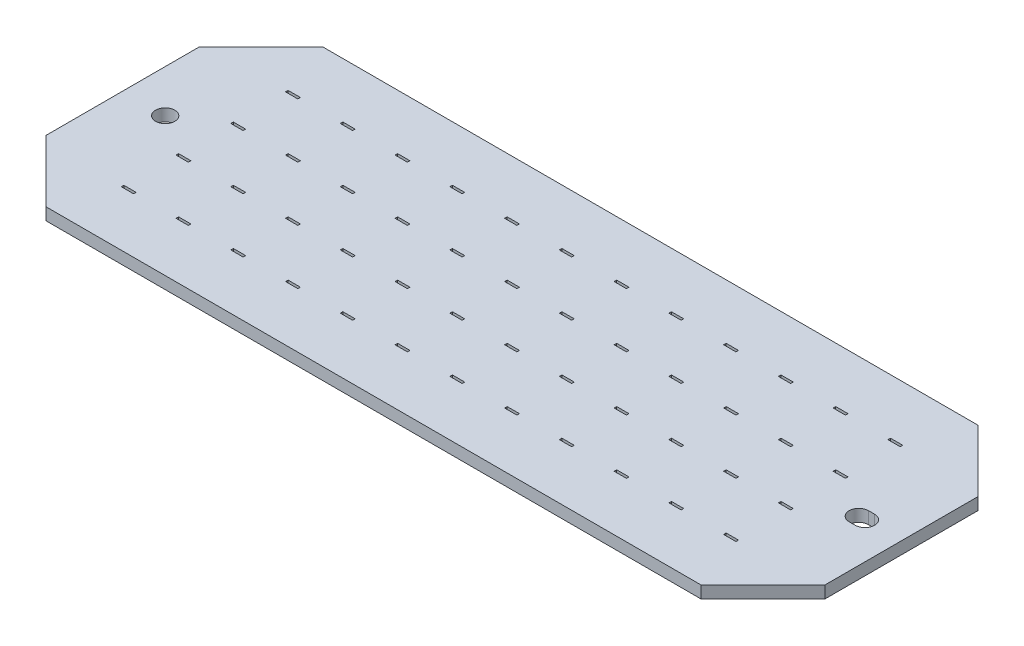
from build123d import *

# Parameters (mm, degrees)
SKETCH1_W      = 64
SKETCH1_H      = 22.75
EXTRUDE1_DEPTH = 1
CHAMFER1_SIZE  = 5.08
SKETCH4_R      = 0.79375
EXTRUDE2_DEPTH = 2
SKETCH5_W      = 1.01
SKETCH5_H      = 0.21
EXTRUDE5_DEPTH = 2
EXTRUDE5_TAPER = -4


with BuildPart() as part:
    # Sketch1 → Extrude1 (new body)
    with BuildSketch(Plane(origin=(0, 0, 0), x_dir=(1, 0, 0), z_dir=(0, 1, 0))):
        Rectangle(SKETCH1_W, SKETCH1_H)
    extrude(amount=-EXTRUDE1_DEPTH)

    # Chamfer1
    chamfer1_edges = [part.edges().sort_by_distance(p)[0] for p in [
        (32, -0.5, 11.375),
        (-32, -0.5, 11.375),
        (-32, -0.5, -11.375),
        (32, -0.5, -11.375),
    ]]
    chamfer(chamfer1_edges, length=CHAMFER1_SIZE)

    # Sketch4 → Extrude2 (cut, through all)
    with BuildSketch(Plane(origin=(0, 0, 0), x_dir=(1, 0, 0), z_dir=(0, 1, 0))):
        with Locations((-28.5, 0)):
            Circle(SKETCH4_R)
        with BuildLine():
            Line((29, 0.79375), (28.5, 0.79375))
            ThreePointArc((28.5, 0.79375), (27.70625, 0), (28.5, -0.79375))
            Line((28.5, -0.79375), (29, -0.79375))
            ThreePointArc((29, -0.79375), (29.79375, 0), (29, 0.79375))
        make_face()
    extrude(amount=-EXTRUDE2_DEPTH, mode=Mode.SUBTRACT)

    # Sketch5 → Extrude5 (cut, through all)
    with BuildSketch(Plane(origin=(0, 0, 0), x_dir=(-1, 0, 0), z_dir=(0, 1, 0))):
        with Locations((20.25, -6.75)):
            Rectangle(SKETCH5_W, SKETCH5_H)
        with Locations((24.75, -6.75)):
            Rectangle(SKETCH5_W, SKETCH5_H)
        with Locations((15.75, -6.75)):
            Rectangle(SKETCH5_W, SKETCH5_H)
        with Locations((11.25, -6.75)):
            Rectangle(SKETCH5_W, SKETCH5_H)
        with Locations((6.75, -6.75)):
            Rectangle(SKETCH5_W, SKETCH5_H)
        with Locations((2.25, -6.75)):
            Rectangle(SKETCH5_W, SKETCH5_H)
        with Locations((-2.25, -6.75)):
            Rectangle(SKETCH5_W, SKETCH5_H)
        with Locations((-6.75, -6.75)):
            Rectangle(SKETCH5_W, SKETCH5_H)
        with Locations((-11.25, -6.75)):
            Rectangle(SKETCH5_W, SKETCH5_H)
        with Locations((-15.75, -6.75)):
            Rectangle(SKETCH5_W, SKETCH5_H)
        with Locations((-20.25, -6.75)):
            Rectangle(SKETCH5_W, SKETCH5_H)
        with Locations((-24.75, -6.75)):
            Rectangle(SKETCH5_W, SKETCH5_H)
        with Locations((24.75, -2.25)):
            Rectangle(SKETCH5_W, SKETCH5_H)
        with Locations((20.25, -2.25)):
            Rectangle(SKETCH5_W, SKETCH5_H)
        with Locations((15.75, -2.25)):
            Rectangle(SKETCH5_W, SKETCH5_H)
        with Locations((11.25, -2.25)):
            Rectangle(SKETCH5_W, SKETCH5_H)
        with Locations((6.75, -2.25)):
            Rectangle(SKETCH5_W, SKETCH5_H)
        with Locations((2.25, -2.25)):
            Rectangle(SKETCH5_W, SKETCH5_H)
        with Locations((-2.25, -2.25)):
            Rectangle(SKETCH5_W, SKETCH5_H)
        with Locations((-6.75, -2.25)):
            Rectangle(SKETCH5_W, SKETCH5_H)
        with Locations((-11.25, -2.25)):
            Rectangle(SKETCH5_W, SKETCH5_H)
        with Locations((-15.75, -2.25)):
            Rectangle(SKETCH5_W, SKETCH5_H)
        with Locations((-20.25, -2.25)):
            Rectangle(SKETCH5_W, SKETCH5_H)
        with Locations((-24.75, -2.25)):
            Rectangle(SKETCH5_W, SKETCH5_H)
        with Locations((24.75, 2.25)):
            Rectangle(SKETCH5_W, SKETCH5_H)
        with Locations((20.25, 2.25)):
            Rectangle(SKETCH5_W, SKETCH5_H)
        with Locations((15.75, 2.25)):
            Rectangle(SKETCH5_W, SKETCH5_H)
        with Locations((11.25, 2.25)):
            Rectangle(SKETCH5_W, SKETCH5_H)
        with Locations((6.75, 2.25)):
            Rectangle(SKETCH5_W, SKETCH5_H)
        with Locations((2.25, 2.25)):
            Rectangle(SKETCH5_W, SKETCH5_H)
        with Locations((-2.25, 2.25)):
            Rectangle(SKETCH5_W, SKETCH5_H)
        with Locations((-6.75, 2.25)):
            Rectangle(SKETCH5_W, SKETCH5_H)
        with Locations((-11.25, 2.25)):
            Rectangle(SKETCH5_W, SKETCH5_H)
        with Locations((-15.75, 2.25)):
            Rectangle(SKETCH5_W, SKETCH5_H)
        with Locations((-20.25, 2.25)):
            Rectangle(SKETCH5_W, SKETCH5_H)
        with Locations((-24.75, 2.25)):
            Rectangle(SKETCH5_W, SKETCH5_H)
        with Locations((24.75, 6.75)):
            Rectangle(SKETCH5_W, SKETCH5_H)
        with Locations((20.25, 6.75)):
            Rectangle(SKETCH5_W, SKETCH5_H)
        with Locations((15.75, 6.75)):
            Rectangle(SKETCH5_W, SKETCH5_H)
        with Locations((11.25, 6.75)):
            Rectangle(SKETCH5_W, SKETCH5_H)
        with Locations((6.75, 6.75)):
            Rectangle(SKETCH5_W, SKETCH5_H)
        with Locations((2.25, 6.75)):
            Rectangle(SKETCH5_W, SKETCH5_H)
        with Locations((-2.25, 6.75)):
            Rectangle(SKETCH5_W, SKETCH5_H)
        with Locations((-6.75, 6.75)):
            Rectangle(SKETCH5_W, SKETCH5_H)
        with Locations((-11.25, 6.75)):
            Rectangle(SKETCH5_W, SKETCH5_H)
        with Locations((-15.75, 6.75)):
            Rectangle(SKETCH5_W, SKETCH5_H)
        with Locations((-20.25, 6.75)):
            Rectangle(SKETCH5_W, SKETCH5_H)
        with Locations((-24.75, 6.75)):
            Rectangle(SKETCH5_W, SKETCH5_H)
    extrude(amount=-EXTRUDE5_DEPTH, taper=EXTRUDE5_TAPER, mode=Mode.SUBTRACT)


solid = part.part
